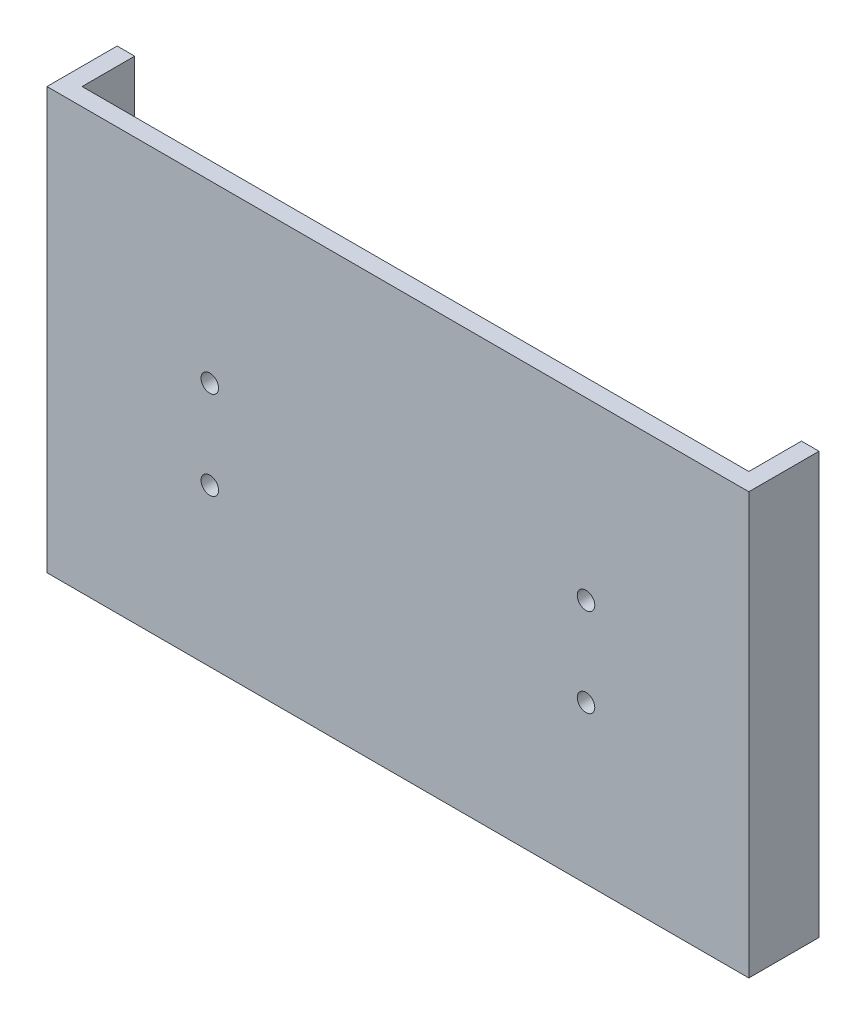
from build123d import *

# Parameters (mm, degrees)
BOSS_EXTRUDE1_DEPTH     = 139.7
SKETCH3_W               = 127
SKETCH3_H               = 63.5
SKETCH3_R               = 1.5875
CUT_EXTRUDE1_DEPTH      = 10.525
CUT_EXTRUDE1_DEPTH_BACK = 4.175


with BuildPart() as part:
    # Sketch2 → Boss-Extrude1 (new body)
    with BuildSketch(Plane(origin=(0, 0, 0), x_dir=(1, 0, 0), z_dir=(0, 1, 0))):
        Polygon((0, 0), (0, 12.7), (3.175, 12.7), (3.175, 3.175), (123.825, 3.175), (123.825, 12.7), (127, 12.7), (127, 0), align=None)
    extrude(amount=BOSS_EXTRUDE1_DEPTH)

    # Sketch3 → Cut-Extrude1 (cut, two sides)
    with BuildSketch(Plane(origin=(0, 0, -3.175), x_dir=(-1, 0, 0), z_dir=(0, 0, -1))) as cut_extrude1_sk:
        with Locations((-63.5, 31.75)):
            Rectangle(SKETCH3_W, SKETCH3_H)
        with Locations((-97.536, 107.95)):
            Circle(SKETCH3_R)
        with Locations((-29.464, 107.95)):
            Circle(SKETCH3_R)
        with Locations((-29.464, 91.948)):
            Circle(SKETCH3_R)
        with Locations((-97.536, 91.948)):
            Circle(SKETCH3_R)
    extrude(amount=CUT_EXTRUDE1_DEPTH, mode=Mode.SUBTRACT)
    extrude(cut_extrude1_sk.sketch, amount=-CUT_EXTRUDE1_DEPTH_BACK, mode=Mode.SUBTRACT)


solid = part.part
